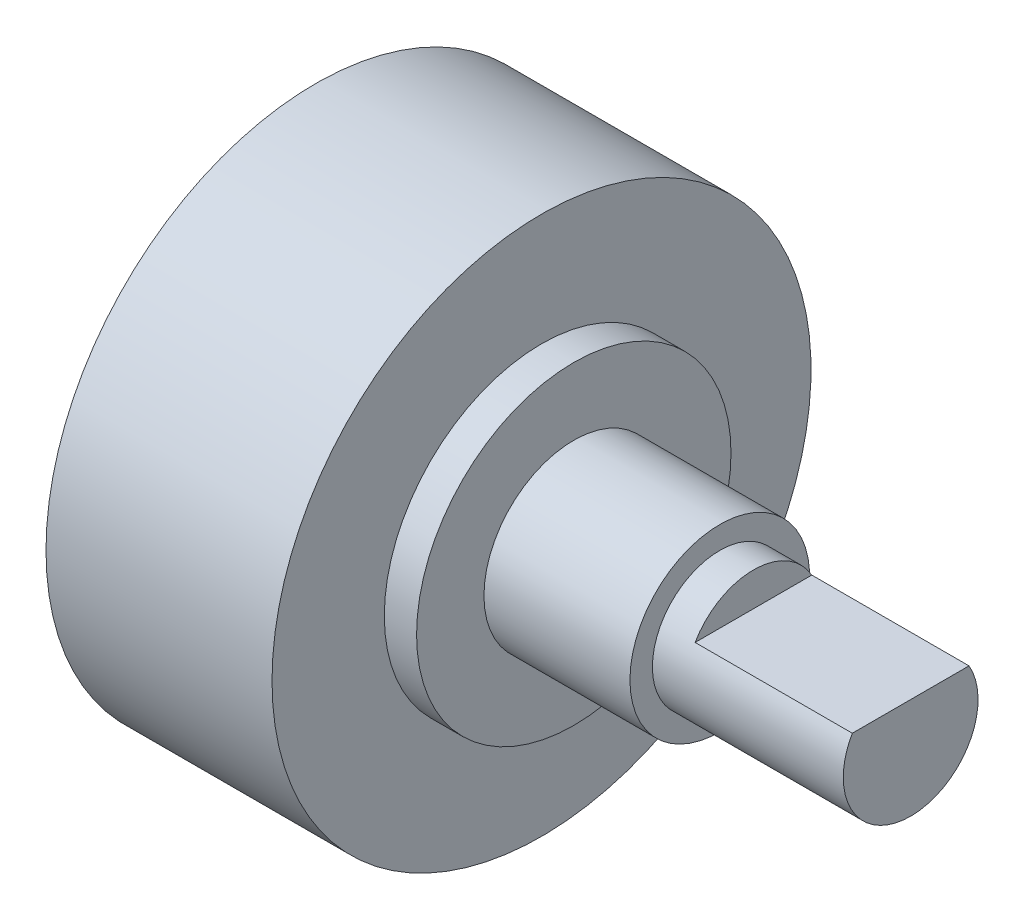
from build123d import *

# Parameters (mm, degrees)
CUT_EXTRUDE1_DEPTH = 7


with BuildPart() as part:
    # Sketch1 → Revolve1 (revolve)
    with BuildSketch(Plane.XY):
        Polygon((0, 0), (26.5, 0), (26.5, 3), (18, 3), (18, 4), (11.5, 4), (11.5, 7), (10.063118771, 7), (10.063118771, 12), (0, 12), align=None)
    revolve(axis=Axis((0, 0, 0), (1, 0, 0)))

    # Sketch2 → Cut-Extrude1 (cut)
    with BuildSketch(Plane(origin=(26.5, 0, 0), x_dir=(0, 0, -1), z_dir=(1, 0, 0))):
        with BuildLine():
            Line((-2.598076211, 1.5), (2.598076211, 1.5))
            ThreePointArc((2.598076211, 1.5), (0, 3), (-2.598076211, 1.5))
        make_face()
    extrude(amount=-CUT_EXTRUDE1_DEPTH, mode=Mode.SUBTRACT)


solid = part.part
